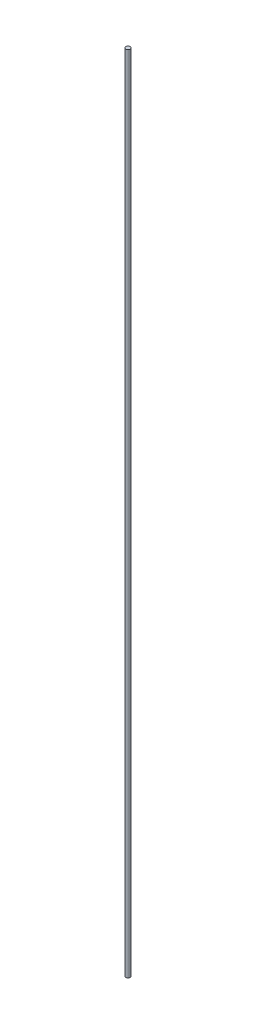
from build123d import *

# Parameters (mm, degrees)
IZIM1_R                     = 4
Y_KSEKLIK_EKSTR_ZYON1_DEPTH = 1400


with BuildPart() as part:
    # Çizim1 → Yükseklik-Ekstrüzyon1 (new body)
    with BuildSketch(Plane(origin=(0, 0, 0), x_dir=(1, 0, 0), z_dir=(0, 1, 0))):
        Circle(IZIM1_R)
    extrude(amount=Y_KSEKLIK_EKSTR_ZYON1_DEPTH)


solid = part.part
